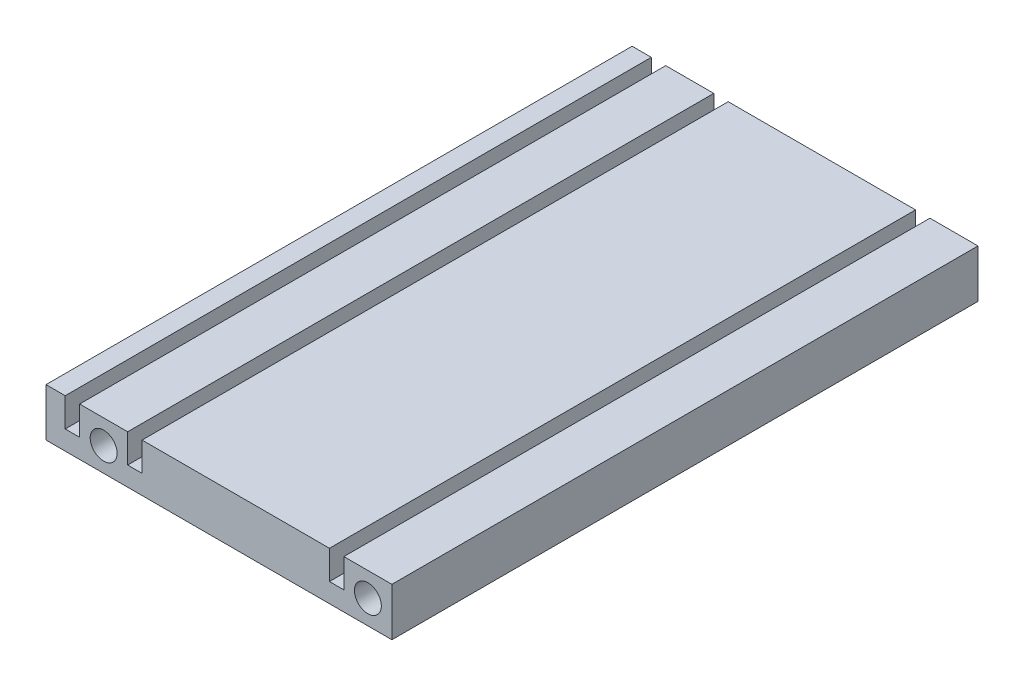
from build123d import *

# Parameters (mm, degrees)
ESQUISSE1_R        = 2.8
BOSS_EXTRU_1_DEPTH = 122


with BuildPart() as part:
    # Esquisse1 → Boss.-Extru.1 (new body)
    with BuildSketch(Plane.XY):
        Polygon((-35.89112663, -3.089603204), (-35.89112663, 6.910396796), (-31.89112663, 6.910396796), (-31.89112663, 0.910396796), (-28.89112663, 0.910396796), (-28.89112663, 6.910396796), (-18.89112663, 6.910396796), (-18.89112663, 0.910396796), (-15.89112663, 0.910396796), (-15.89112663, 6.910396796), (23.10887337, 6.910396796), (23.10887337, 0.910396796), (26.10887337, 0.910396796), (26.10887337, 6.910396796), (36.10887337, 6.910396796), (36.10887337, -3.089603204), align=None)
        with Locations((-23.89112663, 1.910396796)):
            Circle(ESQUISSE1_R, mode=Mode.SUBTRACT)
        with Locations((31.10887337, 1.910396796)):
            Circle(ESQUISSE1_R, mode=Mode.SUBTRACT)
    extrude(amount=BOSS_EXTRU_1_DEPTH)


solid = part.part
